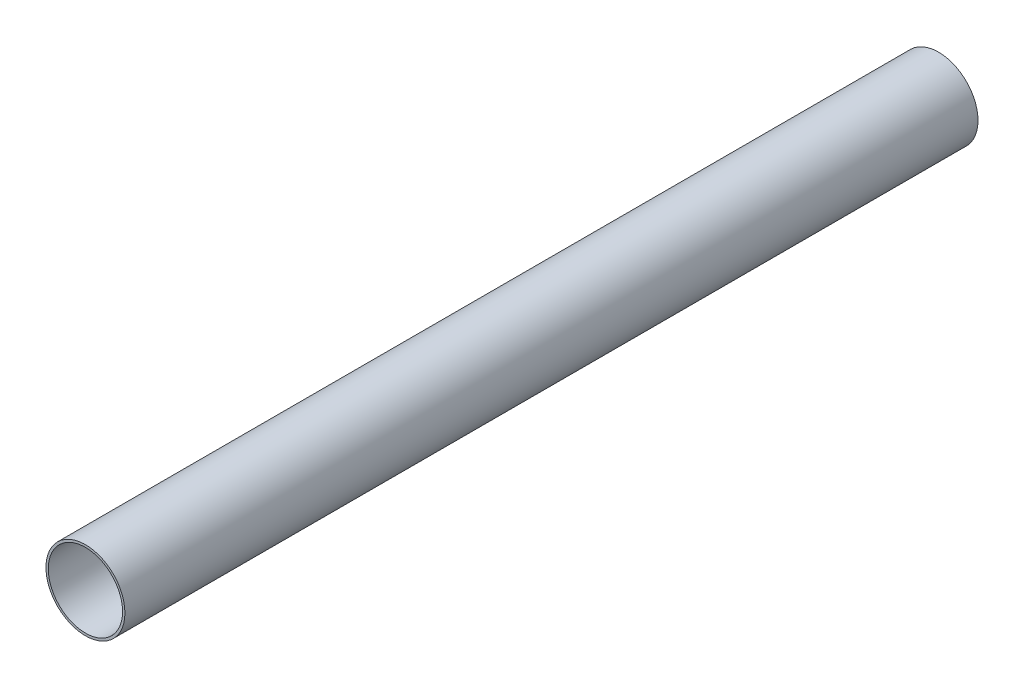
from build123d import *

# Parameters (mm, degrees)
PIPESKETCH_R    = 254
PIPESKETCH_R_2  = 238.9124
EXTRUSION_DEPTH = 5486.4


with BuildPart() as part:
    # PipeSketch → Extrusion (new body)
    with BuildSketch(Plane.XY):
        Circle(PIPESKETCH_R)
        Circle(PIPESKETCH_R_2, mode=Mode.SUBTRACT)
    extrude(amount=EXTRUSION_DEPTH)


solid = part.part
